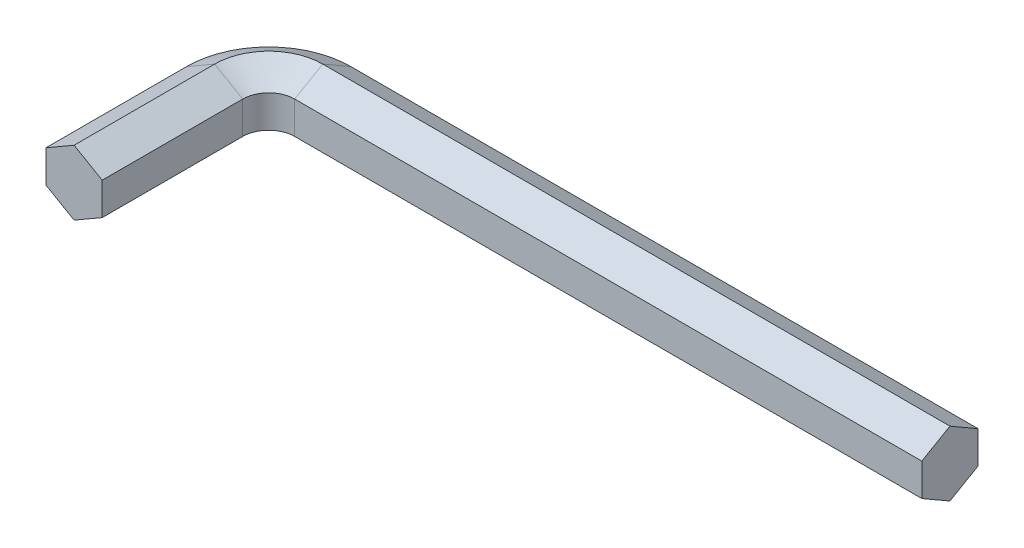
from build123d import *


with BuildPart() as part:
    # Sweep1: sweep along a path in Sketch1
    with BuildLine(Plane(origin=(0, 0, 0), x_dir=(1, 0, 0), z_dir=(0, 1, 0))) as sweep1_path:
        Line((31.5, 11), (-26.5, 11))
        ThreePointArc((-26.5, 11), (-30.035533906, 9.535533906), (-31.5, 6))
        Line((-31.5, 6), (-31.5, -7))
    # Sketch2 → Sweep1 (sweep)
    with BuildSketch(Plane(origin=(31.5, 0, -11), x_dir=(0, 0, -1), z_dir=(1, 0, 0))):
        Polygon((-2.598076211, 1.5), (-2.598076211, -1.5), (0, -3), (2.598076211, -1.5), (2.598076211, 1.5), (0, 3), align=None)
    sweep(path=sweep1_path.line)


solid = part.part
